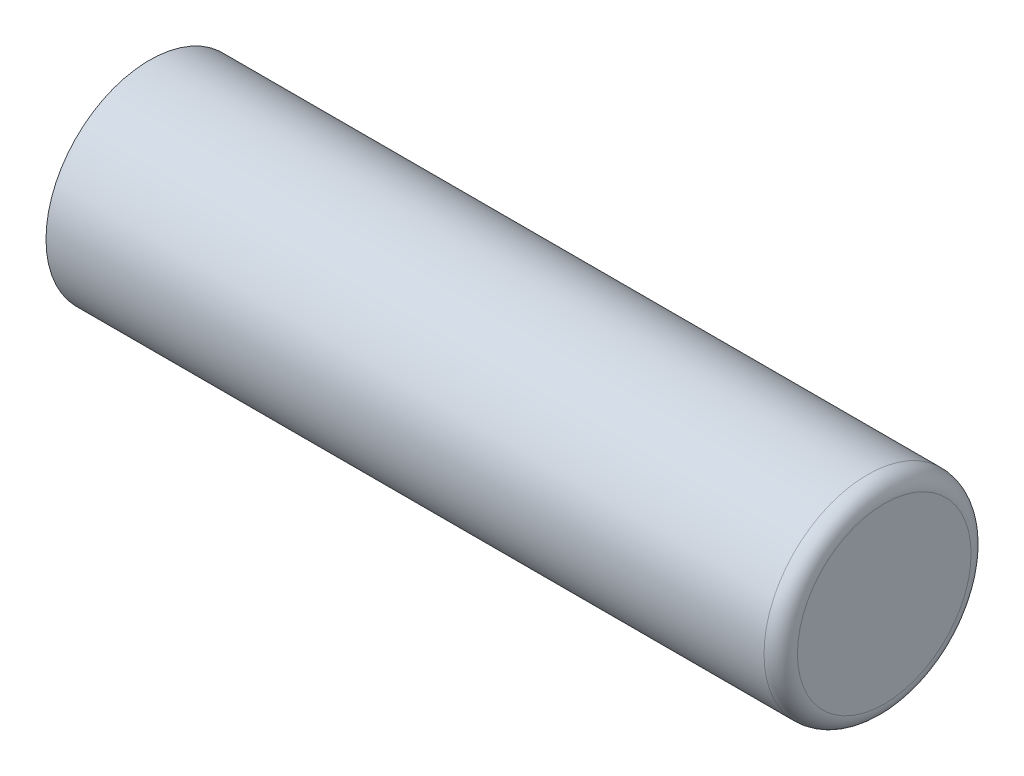
from build123d import *


with BuildPart() as part:
    # Sketch1 → Revolve1 (revolve)
    with BuildSketch(Plane(origin=(0, 0, 0), x_dir=(1, 0, 0), z_dir=(0, 1, 0))):
        with BuildLine():
            Line((-11, 3.1), (10.5, 3.1))
            ThreePointArc((10.5, 3.1), (10.853553391, 2.953553391), (11, 2.6))
            Line((11, 2.6), (11, 0))
            Line((11, 0), (-11, 0))
            Line((-11, 0), (-11, 3.1))
        make_face()
    revolve(axis=Axis((-11, 0, 0), (1, 0, 0)))


solid = part.part
